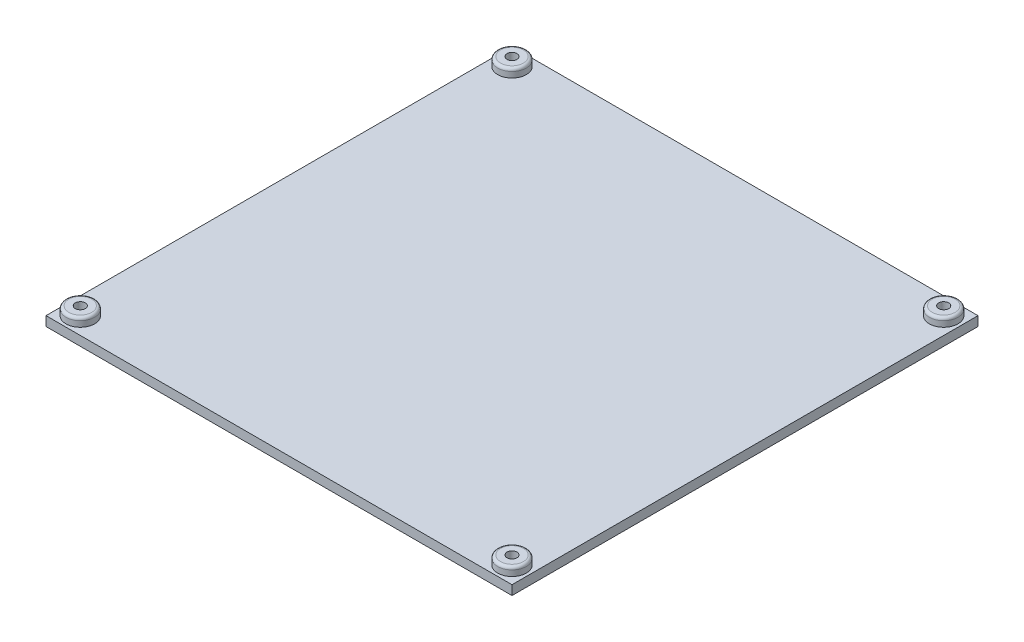
from build123d import *

# Parameters (mm, degrees)
CROQUIS1_W              = 163
CROQUIS1_H              = 163
SALIENTE_EXTRUIR1_DEPTH = 3.3
CROQUIS2_R              = 5
SALIENTE_EXTRUIR2_DEPTH = 3
REDONDEO1_R             = 1
CROQUIS3_R              = 3.25
CORTAR_EXTRUIR1_DEPTH   = 3
CROQUIS4_R              = 1.75
CORTAR_EXTRUIR2_DEPTH   = 6.3


with BuildPart() as part:
    # Croquis1 → Saliente-Extruir1 (new body)
    with BuildSketch(Plane(origin=(0, 0, 0), x_dir=(1, 0, 0), z_dir=(0, 1, 0))):
        Rectangle(CROQUIS1_W, CROQUIS1_H)
    extrude(amount=-SALIENTE_EXTRUIR1_DEPTH)

    # Croquis2 → Saliente-Extruir2 (add)
    with BuildSketch(Plane(origin=(0, 0, 0), x_dir=(1, 0, 0), z_dir=(0, 1, 0))):
        with Locations((-75.5, 75.5)):
            Circle(CROQUIS2_R)
        with Locations((75.5, 75.5)):
            Circle(CROQUIS2_R)
        with Locations((-75.5, -75.5)):
            Circle(CROQUIS2_R)
        with Locations((75.5, -75.5)):
            Circle(CROQUIS2_R)
    extrude(amount=SALIENTE_EXTRUIR2_DEPTH)

    # Redondeo1
    redondeo1_edges = [part.edges().sort_by_distance(p)[0] for p in [
        (70.5, 3, -75.5),
        (-80.5, 3, 75.5),
        (70.5, 3, 75.5),
        (-80.5, 3, -75.5),
    ]]
    fillet(redondeo1_edges, radius=REDONDEO1_R)

    # Croquis3 → Cortar-Extruir1 (cut)
    with BuildSketch(Plane.XZ.offset(3.3)):
        with Locations((-75.5, 75.5)):
            Circle(CROQUIS3_R)
        with Locations((75.5, 75.5)):
            Circle(CROQUIS3_R)
        with Locations((-75.5, -75.5)):
            Circle(CROQUIS3_R)
        with Locations((75.5, -75.5)):
            Circle(CROQUIS3_R)
    extrude(amount=-CORTAR_EXTRUIR1_DEPTH, mode=Mode.SUBTRACT)

    # Croquis4 → Cortar-Extruir2 (cut)
    with BuildSketch(Plane(origin=(0, 3, 0), x_dir=(1, 0, 0), z_dir=(0, 1, 0))):
        with Locations((75.5, -75.5)):
            Circle(CROQUIS4_R)
        with Locations((75.5, 75.5)):
            Circle(CROQUIS4_R)
        with Locations((-75.5, 75.5)):
            Circle(CROQUIS4_R)
        with Locations((-75.5, -75.5)):
            Circle(CROQUIS4_R)
    extrude(amount=-CORTAR_EXTRUIR2_DEPTH, mode=Mode.SUBTRACT)


solid = part.part
